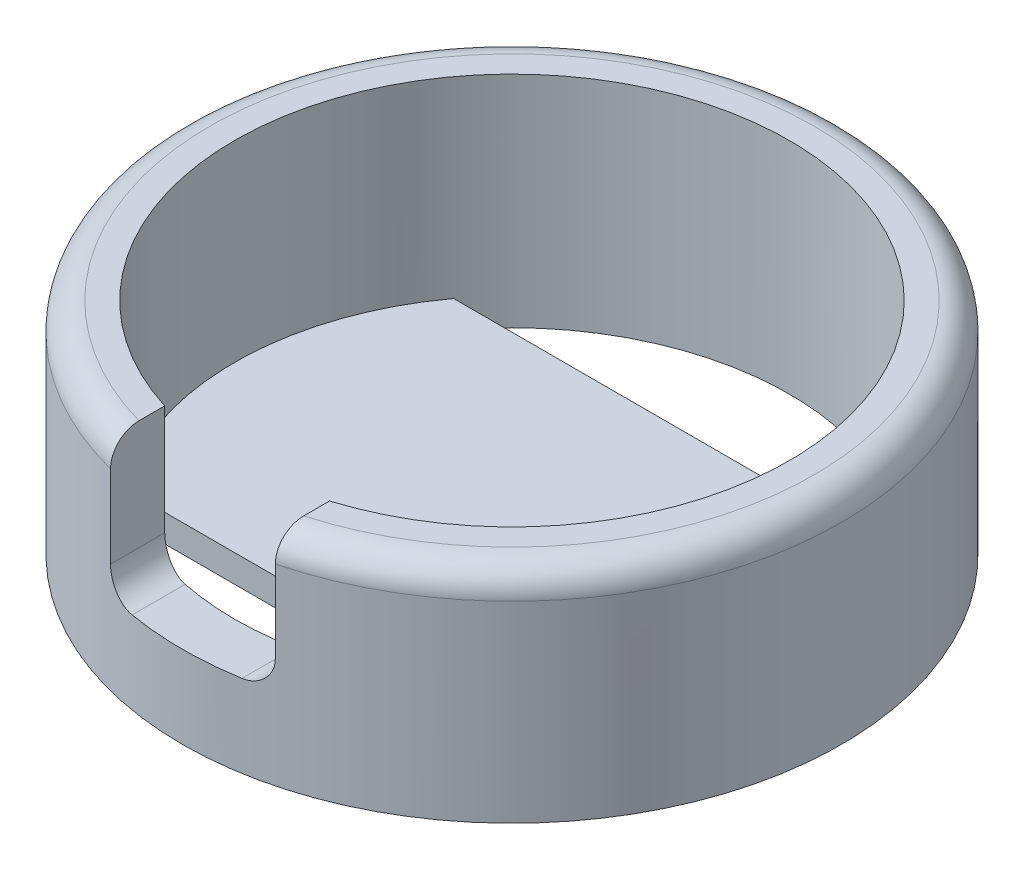
from build123d import *

# Parameters (mm, degrees)
SKETCH1_R           = 6
SKETCH1_R_2         = 5.05
BOSS_EXTRUDE1_DEPTH = 3.5
SKETCH4_R           = 6
BOSS_EXTRUDE2_DEPTH = 0.5
SKETCH5_W           = 3
SKETCH5_H           = 1.177915389
CUT_EXTRUDE3_DEPTH  = 2.5
CUT_EXTRUDE4_DEPTH  = 1.5
FILLET1_R           = 0.5


with BuildPart() as part:
    # Sketch1 → Boss-Extrude1 (new body)
    with BuildSketch(Plane(origin=(0, 0, 0), x_dir=(1, 0, 0), z_dir=(0, 1, 0))):
        Circle(SKETCH1_R)
        Circle(SKETCH1_R_2, mode=Mode.SUBTRACT)
    extrude(amount=BOSS_EXTRUDE1_DEPTH)

    # Sketch4 → Boss-Extrude2 (add)
    with BuildSketch(Plane.XZ):
        Circle(SKETCH4_R)
    extrude(amount=BOSS_EXTRUDE2_DEPTH)

    # Sketch5 → Cut-Extrude3 (cut)
    with BuildSketch(Plane.XZ.offset(-3.5)):
        with Locations((0, 5.411042306)):
            Rectangle(SKETCH5_W, SKETCH5_H)
    extrude(amount=CUT_EXTRUDE3_DEPTH, mode=Mode.SUBTRACT)

    # Sketch7 → Cut-Extrude4 (cut, through all)
    with BuildSketch(Plane(origin=(0, 0, 0), x_dir=(1, 0, 0), z_dir=(0, 1, 0))):
        with BuildLine():
            Line((4.062326919, -3), (-4.062326919, -3))
            ThreePointArc((-4.062326919, -3), (0, -5.05), (4.062326919, -3))
        make_face()
        with BuildLine():
            Line((4.062326919, 3), (-4.062326919, 3))
            ThreePointArc((-4.062326919, 3), (0, 5.05), (4.062326919, 3))
        make_face()
    extrude(amount=-CUT_EXTRUDE4_DEPTH, mode=Mode.SUBTRACT)

    # Fillet1
    fillet1_edges = [part.edges().sort_by_distance(p)[0] for p in [
        (-3.674234614, 3.5, -4.74341649),
        (-1.5, 1, 5.315779815),
        (1.5, 1, 5.315779815),
    ]]
    fillet(fillet1_edges, radius=FILLET1_R)


solid = part.part
